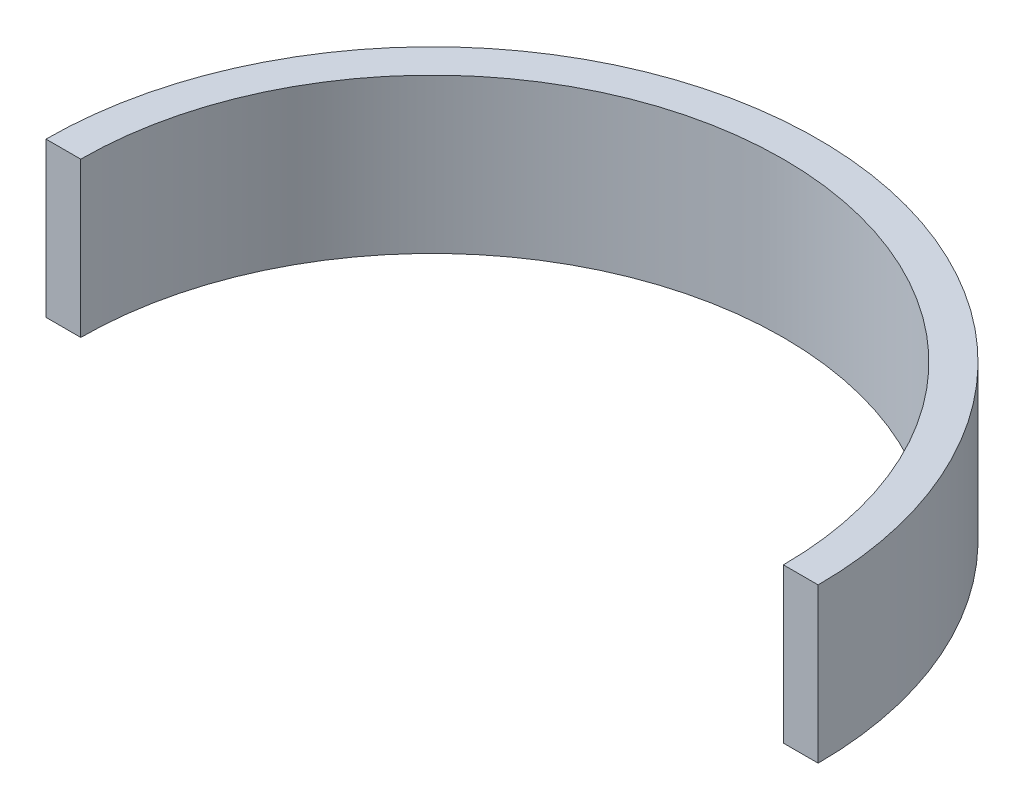
from build123d import *

# Parameters (mm, degrees)
EXTRUDE_1_DEPTH = 20


with BuildPart() as part:
    # 草图1 → 凸台-拉伸1 (new body)
    with BuildSketch(Plane(origin=(0, 0, 0), x_dir=(1, 0, 0), z_dir=(0, 1, 0))):
        with BuildLine():
            Line((-50, 0), (-45.5, 0))
            ThreePointArc((-45.5, 0), (0, 45.5), (45.5, 0))
            Line((45.5, 0), (50, 0))
            ThreePointArc((50, 0), (0, 50), (-50, 0))
        make_face()
    extrude(amount=EXTRUDE_1_DEPTH)


solid = part.part
